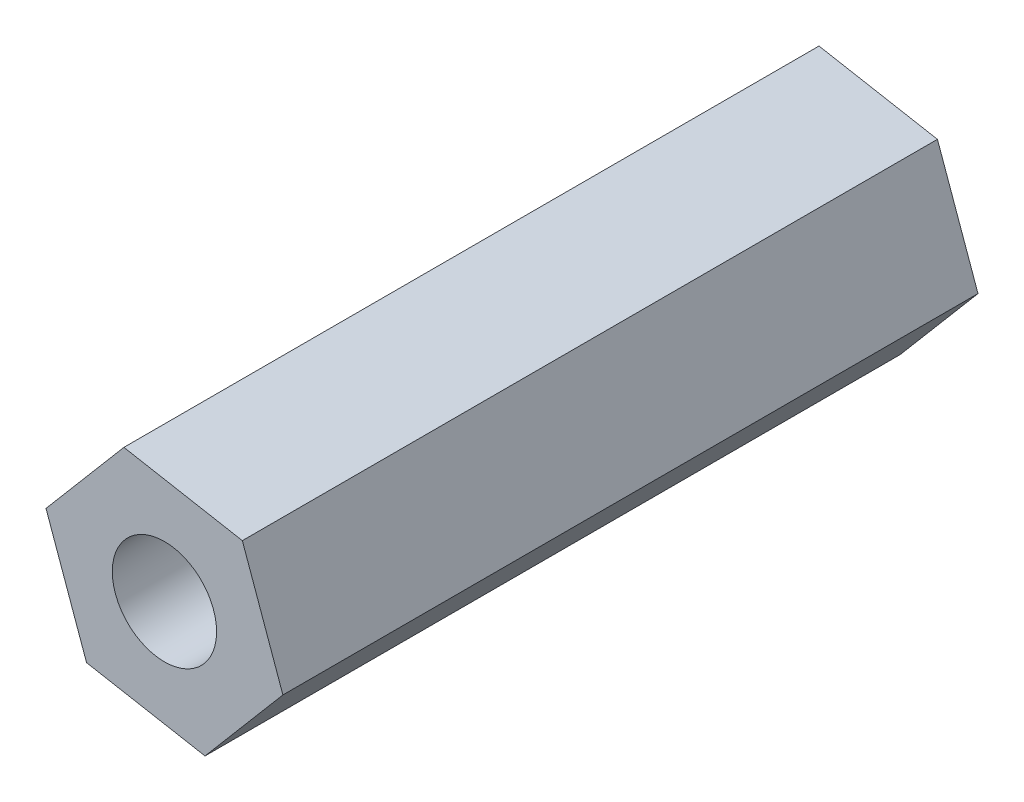
from build123d import *

# Parameters (mm, degrees)
RESSALTO_EXTRUS_O1_DEPTH = 20
ESBO_O4_R                = 1.5
CORTE_EXTRUS_O2_DEPTH    = 40


with BuildPart() as part:
    # Esboço1 → Ressalto-extrusão1 (new body)
    with BuildSketch(Plane.XY):
        Polygon((12.933175524, -4.143885809), (9.525050306, -3.523658029), (7.283854683, -6.165067156), (8.450784277, -9.426704064), (11.858909495, -10.046931845), (14.100105118, -7.405522718), align=None)
    extrude(amount=RESSALTO_EXTRUS_O1_DEPTH)

    # Esboço4 → Corte-extrusão2 (cut)
    with BuildSketch(Plane(origin=(0, 0, 0), x_dir=(-1, 0, 0), z_dir=(0, 0, -1))):
        with Locations((-10.691979901, -6.785294937)):
            Circle(ESBO_O4_R)
    extrude(amount=-CORTE_EXTRUS_O2_DEPTH, mode=Mode.SUBTRACT)


solid = part.part
